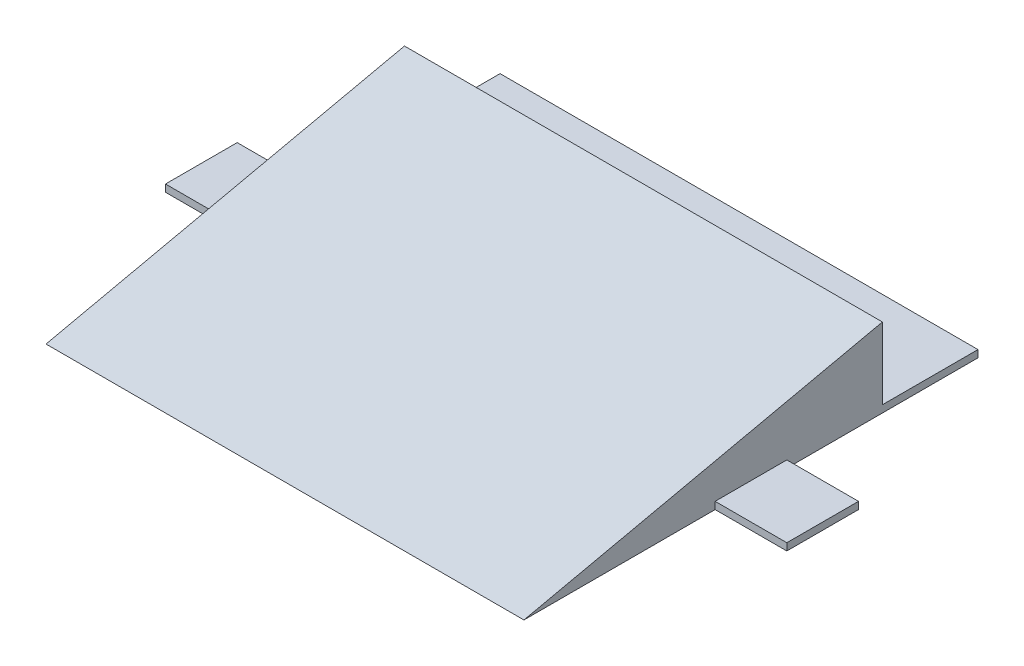
from build123d import *

# Parameters (mm, degrees)
BOSS_EXTRUDE1_DEPTH = 50
SKETCH2_W           = 20
SKETCH2_H           = 1.5
BOSS_EXTRUDE2_DEPTH = 100
SKETCH3_W           = 15
SKETCH3_H           = 15
BOSS_EXTRUDE3_DEPTH = 1.5


with BuildPart() as part:
    # Sketch1 → Boss-Extrude1 (new body, symmetric)
    with BuildSketch(Plane(origin=(0, 0, 0), x_dir=(0, 0, -1), z_dir=(1, 0, 0))):
        Polygon((-75, 0), (0, 16.5), (0, 0), align=None)
    extrude(amount=BOSS_EXTRUDE1_DEPTH, both=True)

    # Sketch2 → Boss-Extrude2 (add)
    with BuildSketch(Plane(origin=(50, 0, 0), x_dir=(0, 0, -1), z_dir=(1, 0, 0))):
        with Locations((10, 0.75)):
            Rectangle(SKETCH2_W, SKETCH2_H)
    extrude(amount=-BOSS_EXTRUDE2_DEPTH)

    # Sketch3 → Boss-Extrude3 (add)
    with BuildSketch(Plane.XZ):
        with Locations((57.5, 27.5)):
            Rectangle(SKETCH3_W, SKETCH3_H)
        with Locations((-57.5, 27.5)):
            Rectangle(SKETCH3_W, SKETCH3_H)
    extrude(amount=-BOSS_EXTRUDE3_DEPTH)


solid = part.part
